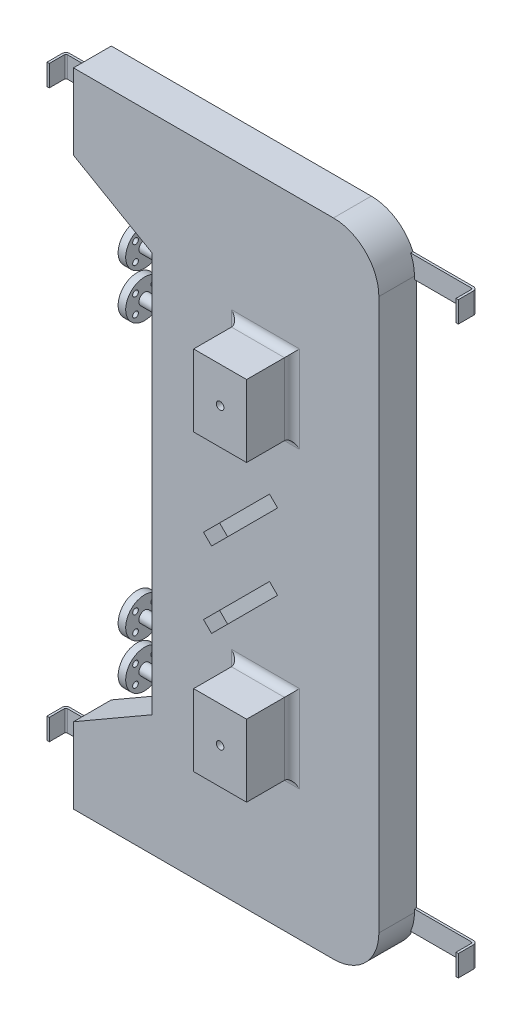
from build123d import *

# Parameters (mm, degrees)
BOSS_EXTRUDE1_DEPTH               = 63.5
CUT_EXTRUDE1_REACH                = 2323.689
SKETCH3_R                         = 6.35
SKETCH5_W                         = 88.9
SKETCH5_H                         = 120.65
BOSS_EXTRUDE2_DEPTH               = 76.2
SKETCH4_R                         = 16.51
CUT_EXTRUDE2_DEPTH                = 25.4
FILLET1_R                         = 12.7
CUT_EXTRUDE3_REACH                = 2327.021
SKETCH6_R                         = 6.35
EXTRUDE_THIN1_DEPTH               = 17.78
BOSS_EXTRUDE3_DEPTH               = 83.82
CUT_EXTRUDE4_REACH                = 2142.249
SKETCH10_R                        = 9.525
SKETCH12_R                        = 9.525
SKETCH13_R                        = 31.75
BOSS_EXTRUDE4_DEPTH               = 12.7
SKETCH15_R                        = 6.985
F_3_8_0_375_DIAMETER_HOLE1_REACH  = 2289.58
F_3_8_0_375_DIAMETER_HOLE1_BORE_R = 4.7625
LPATTERN1_COUNT                   = 2
LPATTERN1_PITCH                   = 76.2
MIRROR2_COPY_1_SKETCH_R           = 9.525
MIRROR2_COPY_2_SKETCH_R           = 31.75
MIRROR2_COPY_2_DEPTH              = 12.7
MIRROR2_COPY_3_SKETCH_R           = 6.985
MIRROR2_COPY_4_REACH              = 2289.58
MIRROR2_COPY_4_SKETCH_R           = 4.7625


with BuildPart() as part:
    # Sketch2 → Boss-Extrude1 (new body)
    with BuildSketch(Plane.XY):
        with BuildLine():
            ThreePointArc((301.927317425, 2142.050810149), (324.245780698, 2195.932346875), (378.127317425, 2218.250810149))
            Line((378.127317425, 2218.250810149), (169.847317425, 2218.250810149))
            Line((169.847317425, 2218.250810149), (169.847317425, 2091.250810149))
            Line((169.847317425, 2091.250810149), (301.927317425, 2015.050810149))
            Line((301.927317425, 2015.050810149), (301.927317425, 2142.050810149))
        make_face()
        with BuildLine():
            Line((606.126925332, 2218.250810149), (378.127317425, 2218.250810149))
            ThreePointArc((378.127317425, 2218.250810149), (324.245780698, 2195.932346875), (301.927317425, 2142.050810149))
            Line((301.927317425, 2142.050810149), (301.927317425, 2015.050810149))
            Line((301.927317425, 2015.050810149), (301.927317425, 1679.607381571))
            Line((301.927317425, 1679.607381571), (327.327317425, 1679.607381571))
            Line((327.327317425, 1679.607381571), (327.327317425, 2142.050810149))
            ThreePointArc((327.327317425, 2142.050810149), (342.20629294, 2177.971834633), (378.127317425, 2192.850810149))
            Line((378.127317425, 2192.850810149), (606.126925332, 2192.850810149))
            ThreePointArc((606.126925332, 2192.850810149), (642.047949816, 2177.971834633), (656.926925332, 2142.050810149))
            Line((656.926925332, 2142.050810149), (656.926925332, 1679.607381571))
            Line((656.926925332, 1679.607381571), (682.326925332, 1679.607381571))
            Line((682.326925332, 1679.607381571), (682.326925332, 2142.050810149))
            ThreePointArc((682.326925332, 2142.050810149), (660.008462058, 2195.932346875), (606.126925332, 2218.250810149))
        make_face()
        with BuildLine():
            Line((599.776925332, 1679.607381571), (656.926925332, 1679.607381571))
            Line((656.926925332, 1679.607381571), (656.926925332, 2142.050810149))
            ThreePointArc((656.926925332, 2142.050810149), (642.047949816, 2177.971834633), (606.126925332, 2192.850810149))
            Line((606.126925332, 2192.850810149), (378.127317425, 2192.850810149))
            ThreePointArc((378.127317425, 2192.850810149), (342.20629294, 2177.971834633), (327.327317425, 2142.050810149))
            Line((327.327317425, 2142.050810149), (327.327317425, 1679.607381571))
            Line((327.327317425, 1679.607381571), (384.477317425, 1679.607381571))
            Line((384.477317425, 1679.607381571), (384.477317425, 2028.051006195))
            ThreePointArc((384.477317425, 2028.051006195), (492.127121378, 2135.700810149), (599.776925332, 2028.051006195))
            Line((599.776925332, 2028.051006195), (599.776925332, 1679.607381571))
        make_face()
        with BuildLine():
            Line((384.477317425, 1679.607381571), (599.776925332, 1679.607381571))
            Line((599.776925332, 1679.607381571), (599.776925332, 2028.051006195))
            ThreePointArc((599.776925332, 2028.051006195), (492.127121378, 2135.700810149), (384.477317425, 2028.051006195))
            Line((384.477317425, 2028.051006195), (384.477317425, 1679.607381571))
        make_face()
        with BuildLine():
            Line((301.927317425, 1217.163952992), (301.927317425, 1344.163952992))
            Line((301.927317425, 1344.163952992), (169.847317425, 1267.963952992))
            Line((169.847317425, 1267.963952992), (169.847317425, 1140.963952992))
            Line((169.847317425, 1140.963952992), (378.127317425, 1140.963952992))
            ThreePointArc((378.127317425, 1140.963952992), (324.245780698, 1163.282416266), (301.927317425, 1217.163952992))
        make_face()
        with BuildLine():
            Line((682.326925332, 1217.163952992), (682.326925332, 1679.607381571))
            Line((682.326925332, 1679.607381571), (656.926925332, 1679.607381571))
            Line((656.926925332, 1679.607381571), (656.926925332, 1217.163952992))
            ThreePointArc((656.926925332, 1217.163952992), (642.047949816, 1181.242928508), (606.126925332, 1166.363952992))
            Line((606.126925332, 1166.363952992), (378.127317425, 1166.363952992))
            ThreePointArc((378.127317425, 1166.363952992), (342.20629294, 1181.242928508), (327.327317425, 1217.163952992))
            Line((327.327317425, 1217.163952992), (327.327317425, 1679.607381571))
            Line((327.327317425, 1679.607381571), (301.927317425, 1679.607381571))
            Line((301.927317425, 1679.607381571), (301.927317425, 1344.163952992))
            Line((301.927317425, 1344.163952992), (301.927317425, 1217.163952992))
            ThreePointArc((301.927317425, 1217.163952992), (324.245780698, 1163.282416266), (378.127317425, 1140.963952992))
            Line((378.127317425, 1140.963952992), (606.126925332, 1140.963952992))
            ThreePointArc((606.126925332, 1140.963952992), (660.008462058, 1163.282416266), (682.326925332, 1217.163952992))
        make_face()
        with BuildLine():
            Line((656.926925332, 1217.163952992), (656.926925332, 1679.607381571))
            Line((656.926925332, 1679.607381571), (599.776925332, 1679.607381571))
            Line((599.776925332, 1679.607381571), (599.776925332, 1331.163756946))
            ThreePointArc((599.776925332, 1331.163756946), (492.127121378, 1223.513952992), (384.477317425, 1331.163756946))
            Line((384.477317425, 1331.163756946), (384.477317425, 1679.607381571))
            Line((384.477317425, 1679.607381571), (327.327317425, 1679.607381571))
            Line((327.327317425, 1679.607381571), (327.327317425, 1217.163952992))
            ThreePointArc((327.327317425, 1217.163952992), (342.20629294, 1181.242928508), (378.127317425, 1166.363952992))
            Line((378.127317425, 1166.363952992), (606.126925332, 1166.363952992))
            ThreePointArc((606.126925332, 1166.363952992), (642.047949816, 1181.242928508), (656.926925332, 1217.163952992))
        make_face()
        with BuildLine():
            Line((599.776925332, 1331.163756946), (599.776925332, 1679.607381571))
            Line((599.776925332, 1679.607381571), (384.477317425, 1679.607381571))
            Line((384.477317425, 1679.607381571), (384.477317425, 1331.163756946))
            ThreePointArc((384.477317425, 1331.163756946), (492.127121378, 1223.513952992), (599.776925332, 1331.163756946))
        make_face()
    extrude(amount=BOSS_EXTRUDE1_DEPTH)

    # Sketch3 → Cut-Extrude1 (cut, up to next)
    with BuildSketch(Plane.XY.offset(63.5), mode=Mode.PRIVATE) as cut_extrude1_sk1:
        with Locations((492.127121378, 1926.427453004)):
            Circle(SKETCH3_R)
    cut_extrude1_tool1 = extrude(cut_extrude1_sk1.sketch, amount=-CUT_EXTRUDE1_REACH, mode=Mode.PRIVATE) & part.part
    # Sketch3 → Cut-Extrude1 (cut, up to next)
    with BuildSketch(Plane.XY.offset(63.5), mode=Mode.PRIVATE) as cut_extrude1_sk2:
        with Locations((492.127121378, 1432.787310137)):
            Circle(SKETCH3_R)
    cut_extrude1_tool2 = extrude(cut_extrude1_sk2.sketch, amount=-CUT_EXTRUDE1_REACH, mode=Mode.PRIVATE) & part.part
    add(cut_extrude1_tool1.solids().sort_by_distance((492.127121, 1926.427453, 63.5))[0], mode=Mode.SUBTRACT)
    add(cut_extrude1_tool2.solids().sort_by_distance((492.127121, 1432.78731, 63.5))[0], mode=Mode.SUBTRACT)

    # Sketch5 → Boss-Extrude2 (add)
    with BuildSketch(Plane.XY.offset(63.5)):
        with Locations((492.127121378, 1926.427453004)):
            Rectangle(SKETCH5_W, SKETCH5_H)
        with Locations((492.127121378, 1432.787310137)):
            Rectangle(SKETCH5_W, SKETCH5_H)
    extrude(amount=BOSS_EXTRUDE2_DEPTH)

    # Sketch4 → Cut-Extrude2 (cut)
    with BuildSketch(Plane(origin=(0, 0, 0), x_dir=(-1, 0, 0), z_dir=(0, 0, -1))):
        with Locations((-492.127121378, 1926.427453004)):
            Circle(SKETCH4_R)
        with Locations((-492.127121378, 1432.787310137)):
            Circle(SKETCH4_R)
    extrude(amount=-CUT_EXTRUDE2_DEPTH, mode=Mode.SUBTRACT)

    # Fillet1
    fillet1_edges = [part.edges().sort_by_distance(p)[0] for p in [
        (536.577121378, 1926.427453004, 63.5),
        (492.127121378, 1986.752453004, 63.5),
        (447.677121378, 1926.427453004, 63.5),
        (492.127121378, 1866.102453004, 63.5),
        (536.577121378, 1432.787310137, 63.5),
        (492.127121378, 1493.112310137, 63.5),
        (447.677121378, 1432.787310137, 63.5),
        (492.127121378, 1372.462310137, 63.5),
    ]]
    fillet(fillet1_edges, radius=FILLET1_R)

    # Sketch6 → Cut-Extrude3 (cut, up to next)
    with BuildSketch(Plane.XY.offset(139.7), mode=Mode.PRIVATE) as cut_extrude3_sk1:
        with Locations((492.127121378, 1926.427453004)):
            Circle(SKETCH6_R)
    cut_extrude3_tool1 = extrude(cut_extrude3_sk1.sketch, amount=-CUT_EXTRUDE3_REACH, mode=Mode.PRIVATE) & part.part
    # Sketch6 → Cut-Extrude3 (cut, up to next)
    with BuildSketch(Plane.XY.offset(139.7), mode=Mode.PRIVATE) as cut_extrude3_sk2:
        with Locations((492.127121378, 1432.787310137)):
            Circle(SKETCH6_R)
    cut_extrude3_tool2 = extrude(cut_extrude3_sk2.sketch, amount=-CUT_EXTRUDE3_REACH, mode=Mode.PRIVATE) & part.part
    add(cut_extrude3_tool1.solids().sort_by_distance((492.127121, 1926.427453, 139.7))[0], mode=Mode.SUBTRACT)
    add(cut_extrude3_tool2.solids().sort_by_distance((492.127121, 1432.78731, 139.7))[0], mode=Mode.SUBTRACT)

    # Sketch8 → Extrude-Thin1 (add, symmetric)
    with BuildSketch(Plane(origin=(0, 1204.463952992, 0), x_dir=(-1, 0, 0), z_dir=(0, -1, 0))):
        with BuildLine():
            Line((-93.647317425, -31.75), (-93.647317425, -6.35))
            ThreePointArc((-93.647317425, -6.35), (-95.507189364, -1.859871939), (-99.997317425, 0))
            Line((-99.997317425, 0), (-777.576925332, 0))
            ThreePointArc((-777.576925332, 0), (-782.067053392, -1.859871939), (-783.926925332, -6.35))
            Line((-783.926925332, -6.35), (-783.926925332, -31.75))
            Line((-783.926925332, -31.75), (-780.116925332, -31.75))
            Line((-780.116925332, -31.75), (-780.116925332, -6.35))
            ThreePointArc((-780.116925332, -6.35), (-779.372976556, -4.553948776), (-777.576925332, -3.81))
            Line((-777.576925332, -3.81), (-99.997317425, -3.81))
            ThreePointArc((-99.997317425, -3.81), (-98.201266201, -4.553948776), (-97.457317425, -6.35))
            Line((-97.457317425, -6.35), (-97.457317425, -31.75))
            Line((-97.457317425, -31.75), (-93.647317425, -31.75))
        make_face()
    extrude_thin1 = extrude(amount=EXTRUDE_THIN1_DEPTH, both=True)

    # Mirror1: Extrude-Thin1 across plane
    add(extrude_thin1.mirror(Plane(origin=(0, 1679.607381571, 0), x_dir=(0, 0, 1), z_dir=(0, -1, 0))))

    # Sketch9 → Boss-Extrude3 (add)
    with BuildSketch(Plane.XY.offset(63.5)):
        Polygon((498.862313469, 1763.312957843), (471.921545106, 1736.37218948), (485.391929287, 1722.901805298), (512.332697651, 1749.842573661), align=None)
        Polygon((498.862313469, 1636.312957843), (471.921545106, 1609.37218948), (485.391929287, 1595.901805298), (512.332697651, 1622.842573661), align=None)
    extrude(amount=BOSS_EXTRUDE3_DEPTH)

    # Sketch10 → Cut-Extrude4 (cut, up to next)
    with BuildSketch(Plane(origin=(-555.254938005, 555.254938005, 0), x_dir=(0, 0, -1), z_dir=(0.7071067811865477, -0.7071067811865475, 0)), mode=Mode.PRIVATE) as cut_extrude4_sk1:
        with Locations(Location((-128.27, 1490.746913367, 0), (0, 0, 90))):
            Circle(SKETCH10_R)
    cut_extrude4_tool1 = extrude(cut_extrude4_sk1.sketch, amount=-CUT_EXTRUDE4_REACH, mode=Mode.PRIVATE) & part.part
    # Sketch10 → Cut-Extrude4 (cut, up to next)
    with BuildSketch(Plane(origin=(-555.254938005, 555.254938005, 0), x_dir=(0, 0, -1), z_dir=(0.7071067811865477, -0.7071067811865475, 0)), mode=Mode.PRIVATE) as cut_extrude4_sk2:
        with Locations(Location((-128.27, 1580.549474577, 0), (0, 0, 90))):
            Circle(SKETCH10_R)
    cut_extrude4_tool2 = extrude(cut_extrude4_sk2.sketch, amount=-CUT_EXTRUDE4_REACH, mode=Mode.PRIVATE) & part.part
    add(cut_extrude4_tool1.solids().sort_by_distance((498.862313, 1609.372189, 128.27))[0], mode=Mode.SUBTRACT)
    add(cut_extrude4_tool2.solids().sort_by_distance((562.362313, 1672.872189, 128.27))[0], mode=Mode.SUBTRACT)

    # Sweep1: sweep along a path in Sketch11
    with BuildLine(Plane.XZ.offset(-1372.462310137)) as sweep1_path:
        Line((257.477317425, 31.75), (365.427317425, 31.75))
        ThreePointArc((365.427317425, 31.75), (374.407573546, 28.030256121), (378.127317425, 19.05))
        Line((378.127317425, 19.05), (378.127317425, 0))
    # Sketch12 → Sweep1 (sweep)
    with BuildSketch(Plane.ZY.offset(-257.477317425)):
        with Locations((31.75, 1372.462310137)):
            Circle(SKETCH12_R)
    sweep1 = sweep(path=sweep1_path.line)

    # Sketch13 → Boss-Extrude4 (add)
    with BuildSketch(Plane.ZY.offset(-257.477317425)):
        with Locations(Location((31.75, 1372.462310137, 0), (0, 0, 180))):
            Circle(SKETCH13_R)
    boss_extrude4 = extrude(amount=BOSS_EXTRUDE4_DEPTH)

    # Cut-Sweep1: sweep along a path in Sketch14
    with BuildLine(Plane.XZ.offset(-1372.462310137)) as cut_sweep1_path:
        Line((378.127317425, 0), (378.127317425, 19.05))
        ThreePointArc((378.127317425, 19.05), (374.407573546, 28.030256121), (365.427317425, 31.75))
        Line((365.427317425, 31.75), (257.477317425, 31.75))
        Line((257.477317425, 31.75), (244.777317425, 31.75))
    # Sketch15 → Cut-Sweep1 (sweep, cut)
    with BuildSketch(Plane.ZY.offset(-244.777317425)):
        with Locations((31.75, 1372.462310137)):
            Circle(SKETCH15_R)
    cut_sweep1 = sweep(path=cut_sweep1_path.line, mode=Mode.SUBTRACT)

    # 3/8 (0.375) Diameter Hole1 bore → 3/8 (0.375) Diameter Hole1 (cut, up to next)
    with BuildSketch(Plane.ZY.offset(-244.777317425), mode=Mode.PRIVATE) as f_3_8_0_375_diameter_hole1_sk1:
        with Locations((46.99, 1387.702310137)):
            Circle(F_3_8_0_375_DIAMETER_HOLE1_BORE_R)
    f_3_8_0_375_diameter_hole1_tool1 = extrude(f_3_8_0_375_diameter_hole1_sk1.sketch, amount=-F_3_8_0_375_DIAMETER_HOLE1_REACH, mode=Mode.PRIVATE) & part.part
    # 3/8 (0.375) Diameter Hole1 bore → 3/8 (0.375) Diameter Hole1 (cut, up to next)
    with BuildSketch(Plane.ZY.offset(-244.777317425), mode=Mode.PRIVATE) as f_3_8_0_375_diameter_hole1_sk2:
        with Locations((46.99, 1357.222310137)):
            Circle(F_3_8_0_375_DIAMETER_HOLE1_BORE_R)
    f_3_8_0_375_diameter_hole1_tool2 = extrude(f_3_8_0_375_diameter_hole1_sk2.sketch, amount=-F_3_8_0_375_DIAMETER_HOLE1_REACH, mode=Mode.PRIVATE) & part.part
    # 3/8 (0.375) Diameter Hole1 bore → 3/8 (0.375) Diameter Hole1 (cut, up to next)
    with BuildSketch(Plane.ZY.offset(-244.777317425), mode=Mode.PRIVATE) as f_3_8_0_375_diameter_hole1_sk3:
        with Locations((16.51, 1357.222310137)):
            Circle(F_3_8_0_375_DIAMETER_HOLE1_BORE_R)
    f_3_8_0_375_diameter_hole1_tool3 = extrude(f_3_8_0_375_diameter_hole1_sk3.sketch, amount=-F_3_8_0_375_DIAMETER_HOLE1_REACH, mode=Mode.PRIVATE) & part.part
    # 3/8 (0.375) Diameter Hole1 bore → 3/8 (0.375) Diameter Hole1 (cut, up to next)
    with BuildSketch(Plane.ZY.offset(-244.777317425), mode=Mode.PRIVATE) as f_3_8_0_375_diameter_hole1_sk4:
        with Locations((16.51, 1387.702310137)):
            Circle(F_3_8_0_375_DIAMETER_HOLE1_BORE_R)
    f_3_8_0_375_diameter_hole1_tool4 = extrude(f_3_8_0_375_diameter_hole1_sk4.sketch, amount=-F_3_8_0_375_DIAMETER_HOLE1_REACH, mode=Mode.PRIVATE) & part.part
    f_3_8_0_375_diameter_hole1_1 = f_3_8_0_375_diameter_hole1_tool1.solids().sort_by_distance((244.777317, 1387.70231, 46.99))[0]
    add(f_3_8_0_375_diameter_hole1_1, mode=Mode.SUBTRACT)
    f_3_8_0_375_diameter_hole1_2 = f_3_8_0_375_diameter_hole1_tool2.solids().sort_by_distance((244.777317, 1357.22231, 46.99))[0]
    add(f_3_8_0_375_diameter_hole1_2, mode=Mode.SUBTRACT)
    f_3_8_0_375_diameter_hole1_3 = f_3_8_0_375_diameter_hole1_tool3.solids().sort_by_distance((244.777317, 1357.22231, 16.51))[0]
    add(f_3_8_0_375_diameter_hole1_3, mode=Mode.SUBTRACT)
    f_3_8_0_375_diameter_hole1_4 = f_3_8_0_375_diameter_hole1_tool4.solids().sort_by_distance((244.777317, 1387.70231, 16.51))[0]
    add(f_3_8_0_375_diameter_hole1_4, mode=Mode.SUBTRACT)
    f_3_8_0_375_diameter_hole1 = f_3_8_0_375_diameter_hole1_1 + f_3_8_0_375_diameter_hole1_2 + f_3_8_0_375_diameter_hole1_3 + f_3_8_0_375_diameter_hole1_4  # 3/8 (0.375) Diameter Hole1 as one shape, for the pattern or mirror that repeats it

    # LPattern1: Sweep1, Boss-Extrude4, Cut-Sweep1, 3/8 (0.375) Diameter Hole1 ×2
    with Locations(*[(0, i * LPATTERN1_PITCH, 0) for i in range(1, LPATTERN1_COUNT)]):
        add(sweep1)
        add(boss_extrude4)
        add(cut_sweep1, mode=Mode.SUBTRACT)
        add(f_3_8_0_375_diameter_hole1, mode=Mode.SUBTRACT)

    # Mirror2: Sweep1, Boss-Extrude4, Cut-Sweep1, 3/8 (0.375) Diameter Hole1 across plane
    add(sweep1.mirror(Plane(origin=(0, 1679.607381571, 0), x_dir=(0, 0, 1), z_dir=(0, -1, 0))))
    add(boss_extrude4.mirror(Plane(origin=(0, 1679.607381571, 0), x_dir=(0, 0, 1), z_dir=(0, -1, 0))))
    add(cut_sweep1.mirror(Plane(origin=(0, 1679.607381571, 0), x_dir=(0, 0, 1), z_dir=(0, -1, 0))), mode=Mode.SUBTRACT)
    add(f_3_8_0_375_diameter_hole1.mirror(Plane(origin=(0, 1679.607381571, 0), x_dir=(0, 0, 1), z_dir=(0, -1, 0))), mode=Mode.SUBTRACT)

    # Mirror2 copy 1: sweep along a path in Mirror2 copy 1 path
    with BuildLine(Plane(origin=(0, 1910.552453004, 0), x_dir=(1, 0, 0), z_dir=(0, 1, 0))) as mirror2_copy_1_path:
        Line((257.477317425, -31.75), (365.427317425, -31.75))
        ThreePointArc((365.427317425, -31.75), (374.407573546, -28.030256121), (378.127317425, -19.05))
        Line((378.127317425, -19.05), (378.127317425, 0))
    # Mirror2 copy 1 sketch → Mirror2 copy 1 (sweep)
    with BuildSketch(Plane(origin=(257.477317425, 3283.014763141, 0), x_dir=(0, 0, 1), z_dir=(-1, 0, 0))):
        with Locations((31.75, -1372.462310137)):
            Circle(MIRROR2_COPY_1_SKETCH_R)
    sweep(path=mirror2_copy_1_path.line)

    # Mirror2 copy 2 sketch → Mirror2 copy 2 (add)
    with BuildSketch(Plane(origin=(257.477317425, 3283.014763141, 0), x_dir=(0, 0, 1), z_dir=(-1, 0, 0))):
        with Locations((31.75, -1372.462310137)):
            Circle(MIRROR2_COPY_2_SKETCH_R)
    extrude(amount=MIRROR2_COPY_2_DEPTH)

    # Mirror2 copy 3: sweep along a path in Mirror2 copy 3 path
    with BuildLine(Plane(origin=(0, 1910.552453004, 0), x_dir=(1, 0, 0), z_dir=(0, 1, 0))) as mirror2_copy_3_path:
        Line((378.127317425, 0), (378.127317425, -19.05))
        ThreePointArc((378.127317425, -19.05), (374.407573546, -28.030256121), (365.427317425, -31.75))
        Line((365.427317425, -31.75), (257.477317425, -31.75))
        Line((257.477317425, -31.75), (244.777317425, -31.75))
    # Mirror2 copy 3 sketch → Mirror2 copy 3 (sweep, cut)
    with BuildSketch(Plane(origin=(244.777317425, 3283.014763141, 0), x_dir=(0, 0, 1), z_dir=(-1, 0, 0))):
        with Locations((31.75, -1372.462310137)):
            Circle(MIRROR2_COPY_3_SKETCH_R)
    sweep(path=mirror2_copy_3_path.line, mode=Mode.SUBTRACT)

    # Mirror2 copy 4 sketch → Mirror2 copy 4 (cut, up to next)
    with BuildSketch(Plane(origin=(244.777317425, 3283.014763141, 0), x_dir=(0, 0, 1), z_dir=(-1, 0, 0)), mode=Mode.PRIVATE) as mirror2_copy_4_sk1:
        with Locations((46.99, -1387.702310137)):
            Circle(MIRROR2_COPY_4_SKETCH_R)
    mirror2_copy_4_tool1 = extrude(mirror2_copy_4_sk1.sketch, amount=-MIRROR2_COPY_4_REACH, mode=Mode.PRIVATE) & part.part
    # Mirror2 copy 4 sketch → Mirror2 copy 4 (cut, up to next)
    with BuildSketch(Plane(origin=(244.777317425, 3283.014763141, 0), x_dir=(0, 0, 1), z_dir=(-1, 0, 0)), mode=Mode.PRIVATE) as mirror2_copy_4_sk2:
        with Locations((46.99, -1357.222310137)):
            Circle(MIRROR2_COPY_4_SKETCH_R)
    mirror2_copy_4_tool2 = extrude(mirror2_copy_4_sk2.sketch, amount=-MIRROR2_COPY_4_REACH, mode=Mode.PRIVATE) & part.part
    # Mirror2 copy 4 sketch → Mirror2 copy 4 (cut, up to next)
    with BuildSketch(Plane(origin=(244.777317425, 3283.014763141, 0), x_dir=(0, 0, 1), z_dir=(-1, 0, 0)), mode=Mode.PRIVATE) as mirror2_copy_4_sk3:
        with Locations((16.51, -1357.222310137)):
            Circle(MIRROR2_COPY_4_SKETCH_R)
    mirror2_copy_4_tool3 = extrude(mirror2_copy_4_sk3.sketch, amount=-MIRROR2_COPY_4_REACH, mode=Mode.PRIVATE) & part.part
    # Mirror2 copy 4 sketch → Mirror2 copy 4 (cut, up to next)
    with BuildSketch(Plane(origin=(244.777317425, 3283.014763141, 0), x_dir=(0, 0, 1), z_dir=(-1, 0, 0)), mode=Mode.PRIVATE) as mirror2_copy_4_sk4:
        with Locations((16.51, -1387.702310137)):
            Circle(MIRROR2_COPY_4_SKETCH_R)
    mirror2_copy_4_tool4 = extrude(mirror2_copy_4_sk4.sketch, amount=-MIRROR2_COPY_4_REACH, mode=Mode.PRIVATE) & part.part
    add(mirror2_copy_4_tool1.solids().sort_by_distance((244.777317, 1895.312453141, 46.99))[0], mode=Mode.SUBTRACT)
    add(mirror2_copy_4_tool2.solids().sort_by_distance((244.777317, 1925.792453141, 46.99))[0], mode=Mode.SUBTRACT)
    add(mirror2_copy_4_tool3.solids().sort_by_distance((244.777317, 1925.792453141, 16.51))[0], mode=Mode.SUBTRACT)
    add(mirror2_copy_4_tool4.solids().sort_by_distance((244.777317, 1895.312453141, 16.51))[0], mode=Mode.SUBTRACT)


solid = part.part
